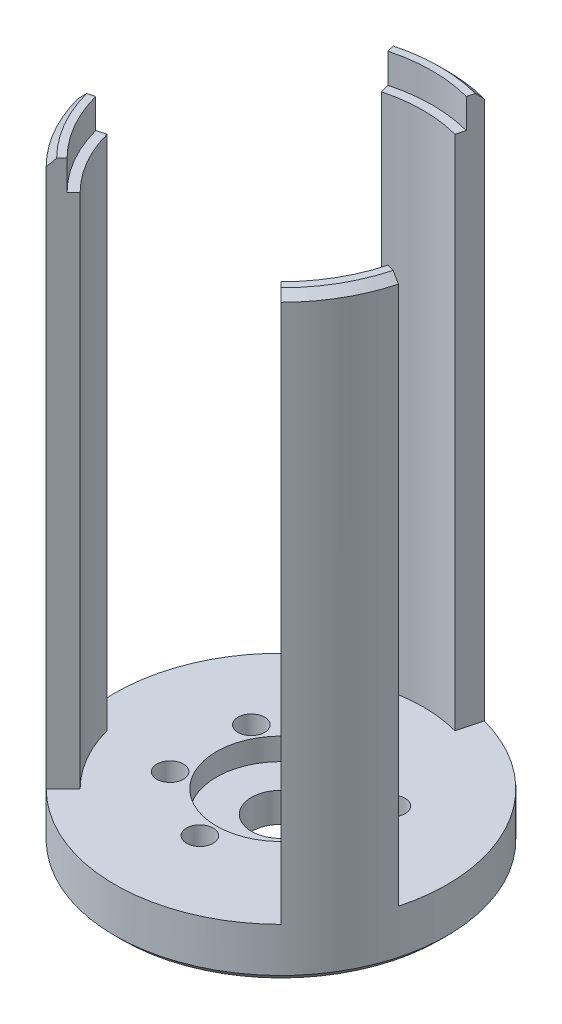
from build123d import *

# Parameters (mm, degrees)
SKETCH1_R           = 22.5
SKETCH1_R_2         = 1.8
SKETCH1_R_3         = 4
BOSS_EXTRUDE1_DEPTH = 7
SKETCH4_R           = 8.75
CUT_EXTRUDE2_DEPTH  = 3
SKETCH6_R           = 3.25
CUT_EXTRUDE3_DEPTH  = 2.5
BOSS_EXTRUDE2_DEPTH = 74
SKETCH7_R           = 20.5
CUT_EXTRUDE4_DEPTH  = 4
CHAMFER2_SIZE       = 1


with BuildPart() as part:
    # Sketch1 → Boss-Extrude1 (new body)
    with BuildSketch(Plane(origin=(0, 0, 0), x_dir=(1, 0, 0), z_dir=(0, 1, 0))):
        Circle(SKETCH1_R)
        with Locations((0, 11)):
            Circle(SKETCH1_R_2, mode=Mode.SUBTRACT)
        with Locations((9.526279442, 5.5)):
            Circle(SKETCH1_R_2, mode=Mode.SUBTRACT)
        with Locations((9.526279442, -5.5)):
            Circle(SKETCH1_R_2, mode=Mode.SUBTRACT)
        with Locations((0, -11)):
            Circle(SKETCH1_R_2, mode=Mode.SUBTRACT)
        with Locations((-9.526279442, -5.5)):
            Circle(SKETCH1_R_2, mode=Mode.SUBTRACT)
        with Locations((-9.526279442, 5.5)):
            Circle(SKETCH1_R_2, mode=Mode.SUBTRACT)
        Circle(SKETCH1_R_3, mode=Mode.SUBTRACT)
    extrude(amount=BOSS_EXTRUDE1_DEPTH)

    # Sketch4 → Cut-Extrude2 (cut)
    with BuildSketch(Plane(origin=(0, 7, 0), x_dir=(1, 0, 0), z_dir=(0, 1, 0))):
        Circle(SKETCH4_R)
    extrude(amount=-CUT_EXTRUDE2_DEPTH, mode=Mode.SUBTRACT)

    # Sketch6 → Cut-Extrude3 (cut)
    with BuildSketch(Plane.XZ):
        with Locations((0, 11)):
            Circle(SKETCH6_R)
        with Locations((9.526279442, -5.5)):
            Circle(SKETCH6_R)
        with Locations((-9.526279442, -5.5)):
            Circle(SKETCH6_R)
    extrude(amount=-CUT_EXTRUDE3_DEPTH, mode=Mode.SUBTRACT)

    # Sketch2 → Boss-Extrude2 (add)
    with BuildSketch(Plane(origin=(0, 7, 0), x_dir=(1, 0, 0), z_dir=(0, 1, 0))):
        with BuildLine():
            Line((4.982266618, 18.594072156), (5.823428515, 21.733331092))
            ThreePointArc((5.823428515, 21.733331092), (0, 22.5), (-5.823428515, 21.733331092))
            Line((-5.823428515, 21.733331092), (-4.982266618, 18.594072156))
            ThreePointArc((-4.982266618, 18.594072156), (0, 19.25), (4.982266618, 18.594072156))
        make_face()
        with BuildLine():
            Line((18.594072156, -4.982266618), (21.733331092, -5.823428515))
            ThreePointArc((21.733331092, -5.823428515), (19.485571585, -11.25), (15.909902577, -15.909902577))
            Line((15.909902577, -15.909902577), (13.611805538, -13.611805538))
            ThreePointArc((13.611805538, -13.611805538), (16.670989023, -9.625), (18.594072156, -4.982266618))
        make_face()
        with BuildLine():
            Line((-13.611805538, -13.611805538), (-15.909902577, -15.909902577))
            ThreePointArc((-15.909902577, -15.909902577), (-19.485571585, -11.25), (-21.733331092, -5.823428515))
            Line((-21.733331092, -5.823428515), (-18.594072156, -4.982266618))
            ThreePointArc((-18.594072156, -4.982266618), (-16.670989023, -9.625), (-13.611805538, -13.611805538))
        make_face()
    extrude(amount=BOSS_EXTRUDE2_DEPTH)

    # Sketch7 → Cut-Extrude4 (cut)
    with BuildSketch(Plane(origin=(0, 81, 0), x_dir=(1, 0, 0), z_dir=(0, 1, 0))):
        Circle(SKETCH7_R)
    extrude(amount=-CUT_EXTRUDE4_DEPTH, mode=Mode.SUBTRACT)

    # Chamfer2
    chamfer2_edges = [part.edges().sort_by_distance(p)[0] for p in [
        (-22.5, 0, 0),
        (19.485571585, 81, 11.25),
        (0, 81, -22.5),
        (-19.485571585, 81, 11.25),
    ]]
    chamfer(chamfer2_edges, length=CHAMFER2_SIZE)


solid = part.part
